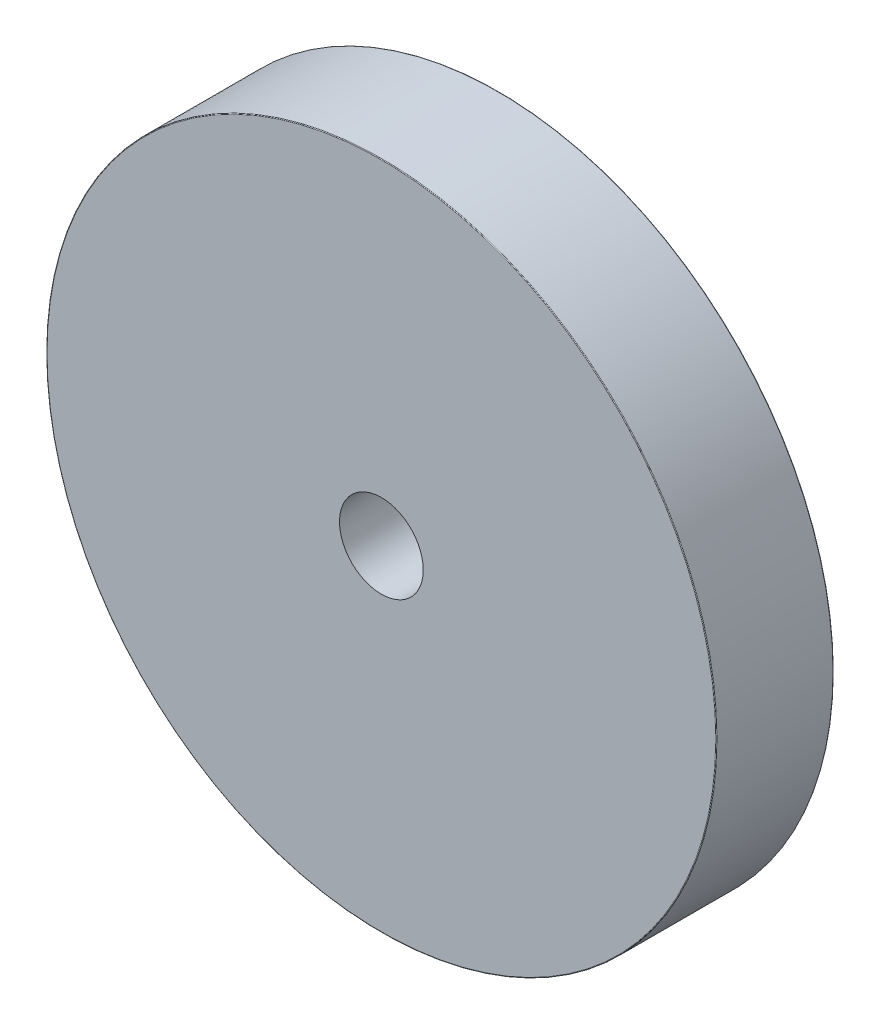
from build123d import *

# Parameters (mm, degrees)
SKETCH1_R      = 12.7
SKETCH1_R_2    = 1.5875
EXTRUDE1_DEPTH = 4.445
FILLET1_R      = 0.0254


with BuildPart() as part:
    # Sketch1 → Extrude1 (new body)
    with BuildSketch(Plane.XY):
        Circle(SKETCH1_R)
        Circle(SKETCH1_R_2, mode=Mode.SUBTRACT)
    extrude(amount=EXTRUDE1_DEPTH)

    # Fillet1
    fillet1_edges = [part.edges().sort_by_distance(p)[0] for p in [
        (-12.7, 0, 0),
        (-12.7, 0, 4.445),
    ]]
    fillet(fillet1_edges, radius=FILLET1_R)


solid = part.part
